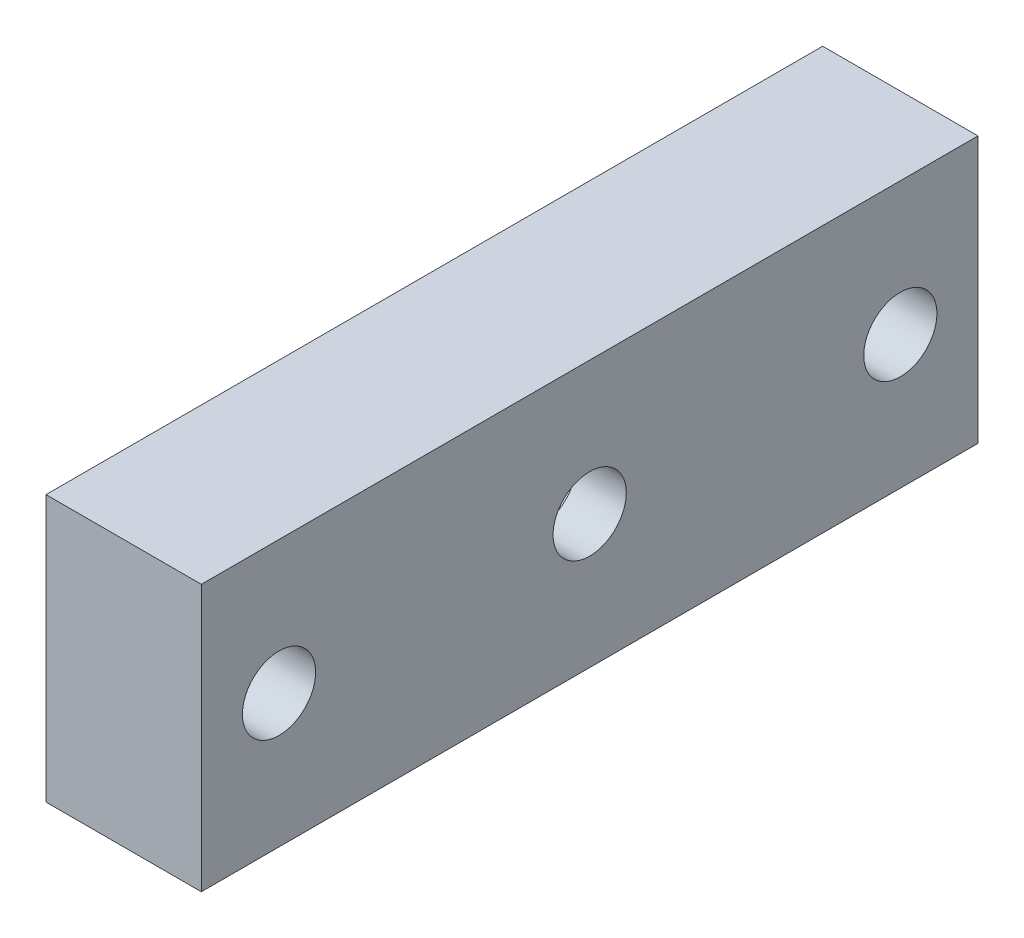
from build123d import *

# Parameters (mm, degrees)
SKETCH1_W           = 35
SKETCH1_H           = 12
SKETCH1_R           = 1.65
BOSS_EXTRUDE1_DEPTH = 7
CUT_EXTRUDE1_START  = -2.25
CUT_EXTRUDE1_DEPTH  = 2.5


with BuildPart() as part:
    # Sketch1 → Boss-Extrude1 (new body)
    with BuildSketch(Plane(origin=(0, 0, 0), x_dir=(0, 0, -1), z_dir=(1, 0, 0))):
        with Locations((17.5, 6)):
            Rectangle(SKETCH1_W, SKETCH1_H)
        with Locations((3.5, 6)):
            Circle(SKETCH1_R, mode=Mode.SUBTRACT)
        with Locations((31.5, 6)):
            Circle(SKETCH1_R, mode=Mode.SUBTRACT)
        with Locations((17.5, 6)):
            Circle(SKETCH1_R, mode=Mode.SUBTRACT)
    extrude(amount=BOSS_EXTRUDE1_DEPTH)

    # Sketch2 → Cut-Extrude1 (cut)
    with BuildSketch(Plane(origin=(7, 0, 0), x_dir=(0, 0, -1), z_dir=(1, 0, 0)).offset(CUT_EXTRUDE1_START)):
        Polygon((20.790896534, 6), (19.145448267, 8.85), (15.854551733, 8.85), (14.209103466, 6), (15.854551733, 3.15), (19.145448267, 3.15), align=None)
    extrude(amount=-CUT_EXTRUDE1_DEPTH, mode=Mode.SUBTRACT)


solid = part.part
